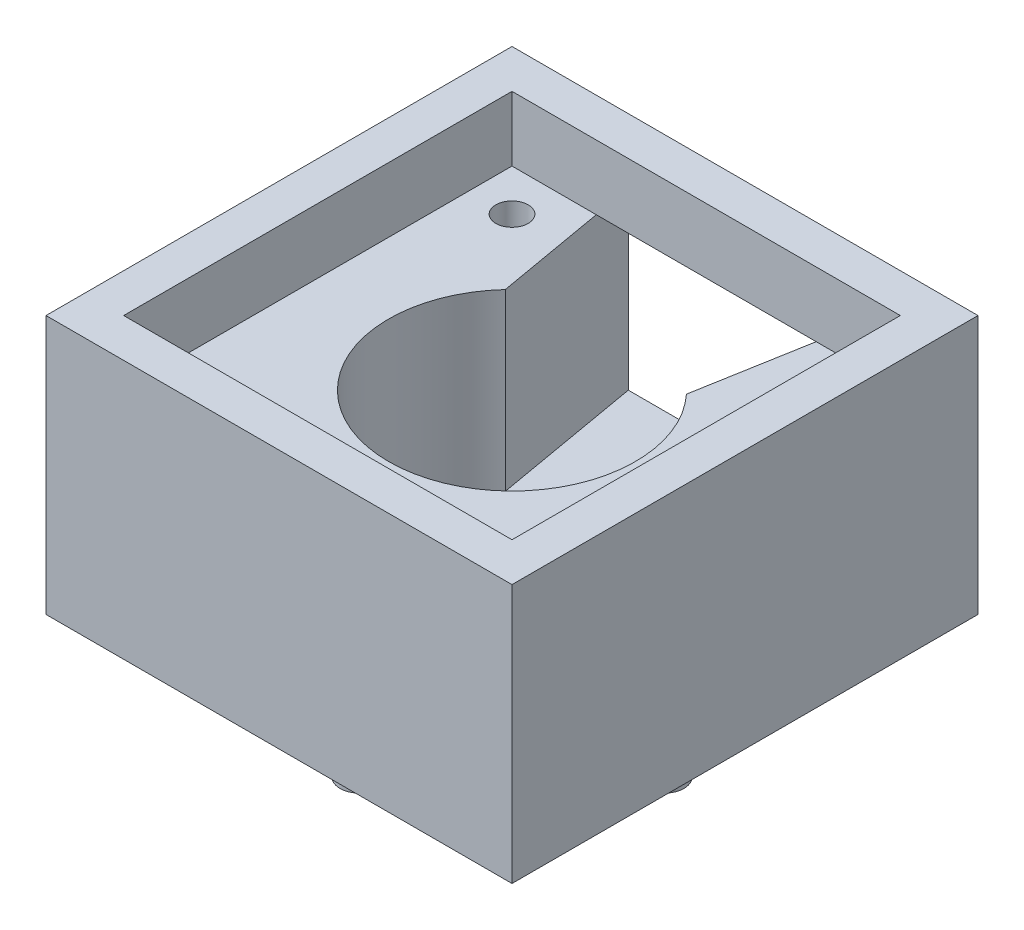
from build123d import *

# Parameters (mm, degrees)
SKETCH1_W           = 72
SKETCH1_H           = 72
BOSS_EXTRUDE1_DEPTH = 40
SKETCH3_W           = 60
SKETCH3_H           = 60
CUT_EXTRUDE1_DEPTH  = 10
SKETCH4_R           = 2.5
CUT_EXTRUDE2_DEPTH  = 30
SKETCH5_R           = 19.075
CUT_EXTRUDE3_DEPTH  = 27
CUT_EXTRUDE5_DEPTH  = 27
SKETCH13_R          = 3
BOSS_EXTRUDE3_DEPTH = 10


with BuildPart() as part:
    # Sketch1 → Boss-Extrude1 (new body)
    with BuildSketch(Plane(origin=(0, 0, 0), x_dir=(1, 0, 0), z_dir=(0, 1, 0))):
        Rectangle(SKETCH1_W, SKETCH1_H)
    extrude(amount=BOSS_EXTRUDE1_DEPTH)

    # Sketch3 → Cut-Extrude1 (cut)
    with BuildSketch(Plane(origin=(0, 40, 0), x_dir=(1, 0, 0), z_dir=(0, 1, 0))):
        Rectangle(SKETCH3_W, SKETCH3_H)
    extrude(amount=-CUT_EXTRUDE1_DEPTH, mode=Mode.SUBTRACT)

    # Sketch4 → Cut-Extrude2 (cut)
    with BuildSketch(Plane(origin=(0, 30, 0), x_dir=(1, 0, 0), z_dir=(0, 1, 0))):
        with Locations((-23.57, 23.57)):
            Circle(SKETCH4_R)
        with Locations((23.57, 23.57)):
            Circle(SKETCH4_R)
        with Locations((23.57, -23.57)):
            Circle(SKETCH4_R)
        with Locations((-23.57, -23.57)):
            Circle(SKETCH4_R)
    extrude(amount=-CUT_EXTRUDE2_DEPTH, mode=Mode.SUBTRACT)

    # Sketch5 → Cut-Extrude3 (cut)
    with BuildSketch(Plane(origin=(0, 30, 0), x_dir=(1, 0, 0), z_dir=(0, 1, 0))):
        Circle(SKETCH5_R)
    extrude(amount=-CUT_EXTRUDE3_DEPTH, mode=Mode.SUBTRACT)

    # Sketch6 → Cut-Extrude5 (cut)
    with BuildSketch(Plane(origin=(0, 30, 0), x_dir=(1, 0, 0), z_dir=(0, 1, 0))):
        with BuildLine():
            Line((-13.99552044, 12.960749693), (-18.030218489, 36))
            Line((-18.030218489, 36), (18.058704295, 36))
            Line((18.058704295, 36), (13.99552044, 12.960749693))
            ThreePointArc((13.99552044, 12.960749693), (0, 19.075), (-13.99552044, 12.960749693))
        make_face()
    extrude(amount=-CUT_EXTRUDE5_DEPTH, mode=Mode.SUBTRACT)

    # Sketch13 → Boss-Extrude3 (add)
    with BuildSketch(Plane.XZ):
        with Locations((0, 23.57)):
            Circle(SKETCH13_R)
        with Locations((23.57, 0)):
            Circle(SKETCH13_R)
        with Locations((-23.57, 0)):
            Circle(SKETCH13_R)
    extrude(amount=BOSS_EXTRUDE3_DEPTH)


solid = part.part
